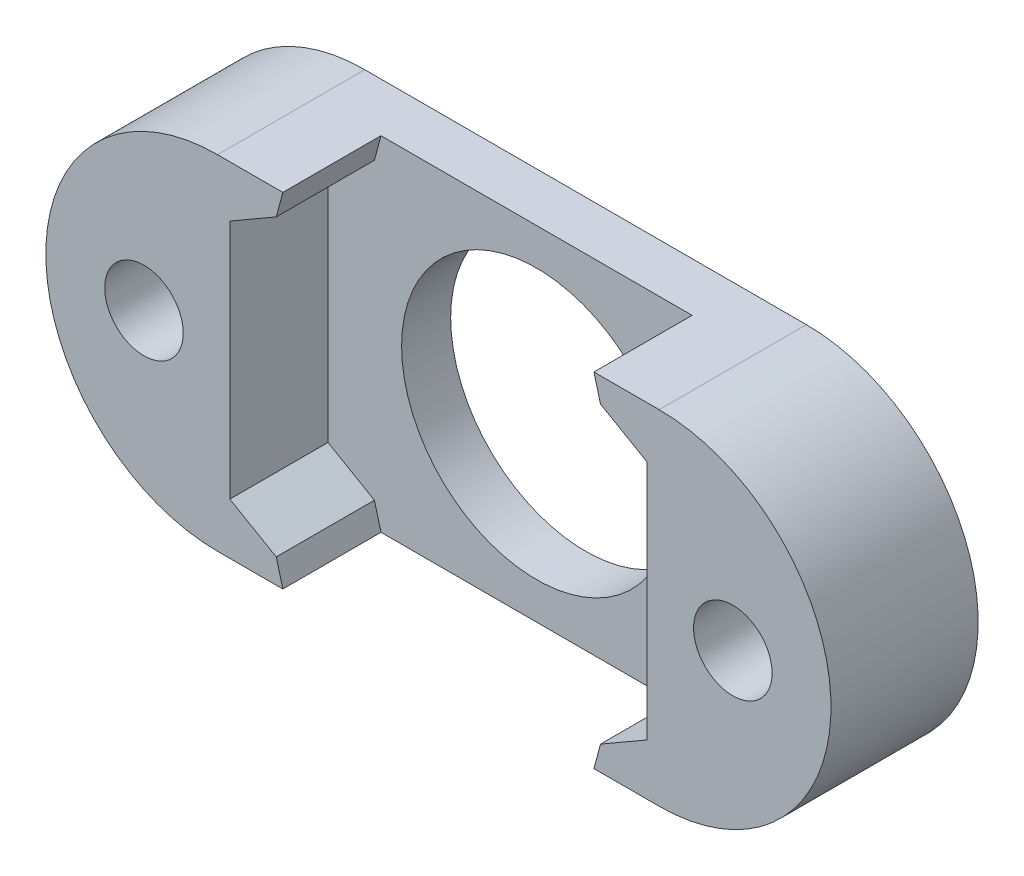
from build123d import *
from OCP.BRepFilletAPI import BRepFilletAPI_MakeChamfer

# Parameters (mm, degrees)
BOSS_EXTRU_1_DEPTH      = 6
ESQUISSE3_R             = 5.5
ESQUISSE3_R_2           = 1.6
ENL_V_MAT_EXTRU_1_DEPTH = 36.47321166
ENL_V_MAT_EXTRU_2_DEPTH = 4
CHAMFER1_SIZE           = 2
CHAMFER1_SIZE2          = 1.464101615


with BuildPart() as part:
    # Esquisse1 → Boss.-Extru.1 (new body)
    with BuildSketch(Plane.XY):
        with BuildLine():
            Line((-27.254178511, 7), (-9.254178511, 7))
            ThreePointArc((-9.254178511, 7), (-2.254178511, 0), (-9.254178511, -7))
            Line((-9.254178511, -7), (-27.254178511, -7))
            ThreePointArc((-27.254178511, -7), (-34.254178511, 0), (-27.254178511, 7))
        make_face()
    extrude(amount=BOSS_EXTRU_1_DEPTH)

    # Esquisse3 → Enlèv. mat.-Extru.1 (cut, through all)
    with BuildSketch(Plane.XY.offset(6)):
        with Locations((-18.254178511, 0)):
            Circle(ESQUISSE3_R)
        with Locations((-30.254178511, 0)):
            Circle(ESQUISSE3_R_2)
        with Locations((-6.254178511, 0)):
            Circle(ESQUISSE3_R_2)
    extrude(amount=-ENL_V_MAT_EXTRU_1_DEPTH, mode=Mode.SUBTRACT)

    # Esquisse4 → Enlèv. mat.-Extru.2 (cut)
    with BuildSketch(Plane.XY.offset(6)):
        Polygon((-9.754178511, -4.907477288), (-9.754178511, 4.907477288), (-18.254178511, 9.814954576), (-26.754178511, 4.907477288), (-26.754178511, -4.907477288), (-18.254178511, -9.814954576), align=None)
    extrude(amount=-ENL_V_MAT_EXTRU_2_DEPTH, mode=Mode.SUBTRACT)

    # Chamfer1: one chamfer whose edges measure the first distance from different faces: ONE call of the kernel's chamfer builder (chamfer() names one face for all edges)
    chamfer1_edges_1 = [part.edges().sort_by_distance(p)[0] for p in [
        (-13.378534164, -7, 4),
    ]]
    chamfer1_side_1 = [part.faces().sort_by_distance(p)[0] for p in [
        (-11.566356337, -5.953738644, 4),
    ]]
    chamfer1_edges_2 = [part.edges().sort_by_distance(p)[0] for p in [
        (-23.129822858, -7, 4),
    ]]
    chamfer1_side_2 = [part.faces().sort_by_distance(p)[0] for p in [
        (-24.942000685, -5.953738644, 4),
    ]]
    chamfer1_edges_3 = [part.edges().sort_by_distance(p)[0] for p in [
        (-23.129822858, 7, 4),
    ]]
    chamfer1_side_3 = [part.faces().sort_by_distance(p)[0] for p in [
        (-24.942000685, 5.953738644, 4),
    ]]
    chamfer1_edges_4 = [part.edges().sort_by_distance(p)[0] for p in [
        (-13.378534164, 7, 4),
    ]]
    chamfer1_side_4 = [part.faces().sort_by_distance(p)[0] for p in [
        (-11.566356337, 5.953738644, 4),
    ]]
    chamfer1 = BRepFilletAPI_MakeChamfer(part.part.solid().wrapped)
    for e in chamfer1_edges_1:
        chamfer1.Add(CHAMFER1_SIZE, CHAMFER1_SIZE2, e.wrapped, chamfer1_side_1[0].wrapped)  # the first distance lies on this face
    for e in chamfer1_edges_2:
        chamfer1.Add(CHAMFER1_SIZE, CHAMFER1_SIZE2, e.wrapped, chamfer1_side_2[0].wrapped)  # the first distance lies on this face
    for e in chamfer1_edges_3:
        chamfer1.Add(CHAMFER1_SIZE, CHAMFER1_SIZE2, e.wrapped, chamfer1_side_3[0].wrapped)  # the first distance lies on this face
    for e in chamfer1_edges_4:
        chamfer1.Add(CHAMFER1_SIZE, CHAMFER1_SIZE2, e.wrapped, chamfer1_side_4[0].wrapped)  # the first distance lies on this face
    add(Compound.cast(chamfer1.Shape()), mode=Mode.REPLACE)


solid = part.part
